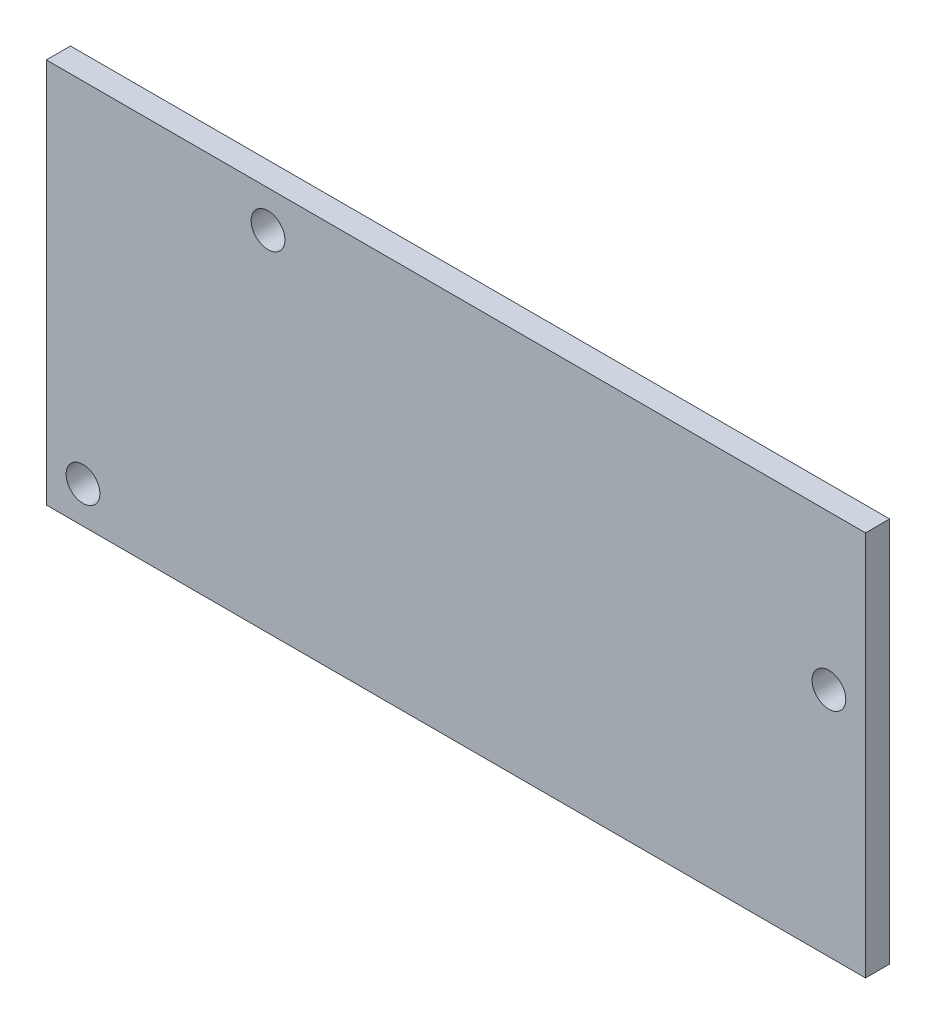
from build123d import *

# Parameters (mm, degrees)
ESQUISSE1_W             = 85
ESQUISSE1_H             = 40
ESQUISSE1_R             = 1.75
BOSS_EXTRU_1_DEPTH      = 2.5
ESQUISSE2_W             = 3
ESQUISSE2_H             = 17
BOSS_EXTRU_2_DEPTH      = 12
ESQUISSE3_R             = 1.75
ENL_V_MAT_EXTRU_1_DEPTH = 59
CONG_1_R                = 2.5


with BuildPart() as part:
    # Esquisse1 → Boss.-Extru.1 (new body)
    with BuildSketch(Plane.XY):
        with Locations((42.5, 20)):
            Rectangle(ESQUISSE1_W, ESQUISSE1_H)
        with Locations((23, 36.2)):
            Circle(ESQUISSE1_R, mode=Mode.SUBTRACT)
        with Locations((3.8, 3.8)):
            Circle(ESQUISSE1_R, mode=Mode.SUBTRACT)
        with Locations((81.2, 24)):
            Circle(ESQUISSE1_R, mode=Mode.SUBTRACT)
    extrude(amount=BOSS_EXTRU_1_DEPTH)

    # Esquisse2 → Boss.-Extru.2 (add)
    with BuildSketch(Plane(origin=(0, 0, 0), x_dir=(-1, 0, 0), z_dir=(0, 0, -1))):
        with Locations((-56.5, 20)):
            Rectangle(ESQUISSE2_W, ESQUISSE2_H)
    extrude(amount=BOSS_EXTRU_2_DEPTH)

    # Esquisse3 → Enlèv. mat.-Extru.1 (cut, through all)
    with BuildSketch(Plane(origin=(58, 0, 0), x_dir=(0, 0, -1), z_dir=(1, 0, 0))):
        with Locations((8.5, 24.25)):
            Circle(ESQUISSE3_R)
        with Locations((8.5, 15.75)):
            Circle(ESQUISSE3_R)
    extrude(amount=-ENL_V_MAT_EXTRU_1_DEPTH, mode=Mode.SUBTRACT)

    # Congé1
    cong_1_edges = [part.edges().sort_by_distance(p)[0] for p in [
        (56.5, 11.5, 0),
        (56.5, 28.5, 0),
        (56.5, 11.5, -12),
        (56.5, 28.5, -12),
    ]]
    fillet(cong_1_edges, radius=CONG_1_R)


solid = part.part
